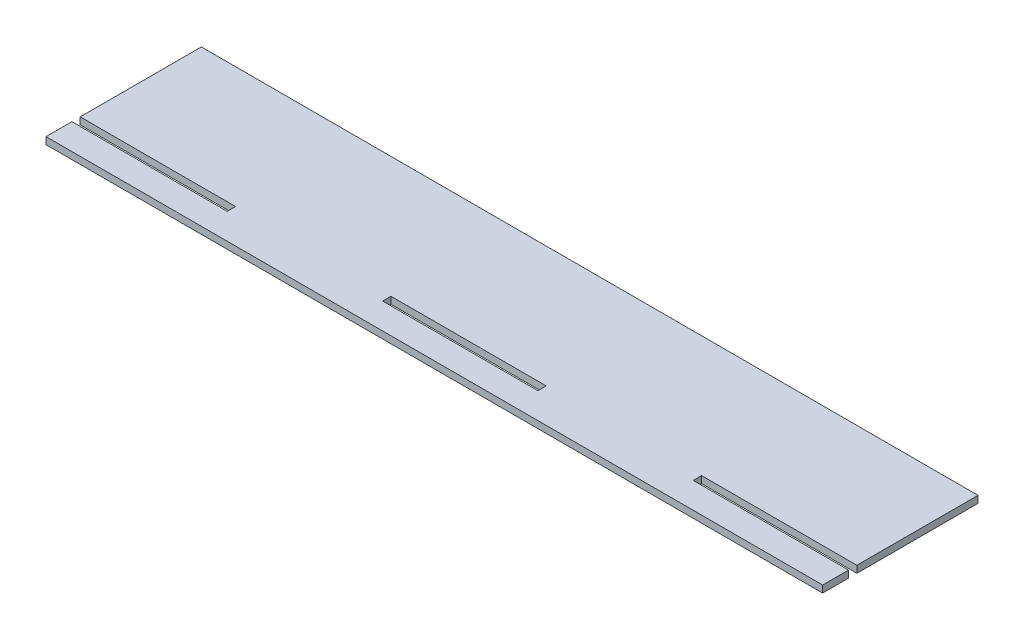
from build123d import *

# Parameters (mm, degrees)
SKETCH1_W           = 60
SKETCH1_H           = 3.218
BOSS_EXTRUDE1_DEPTH = 2.7


with BuildPart() as part:
    # Sketch1 → Boss-Extrude1 (new body)
    with BuildSketch(Plane(origin=(0, 0, 0), x_dir=(1, 0, 0), z_dir=(0, 1, 0))):
        Polygon((-150, -20), (-90, -20), (-90, -16.782), (-150, -16.782), (-150, 30), (150, 30), (150, -16.782), (90, -16.782), (90, -20), (150, -20), (150, -30), (-150, -30), align=None)
        with Locations((0, -18.391)):
            Rectangle(SKETCH1_W, SKETCH1_H, mode=Mode.SUBTRACT)
    extrude(amount=BOSS_EXTRUDE1_DEPTH)


solid = part.part
